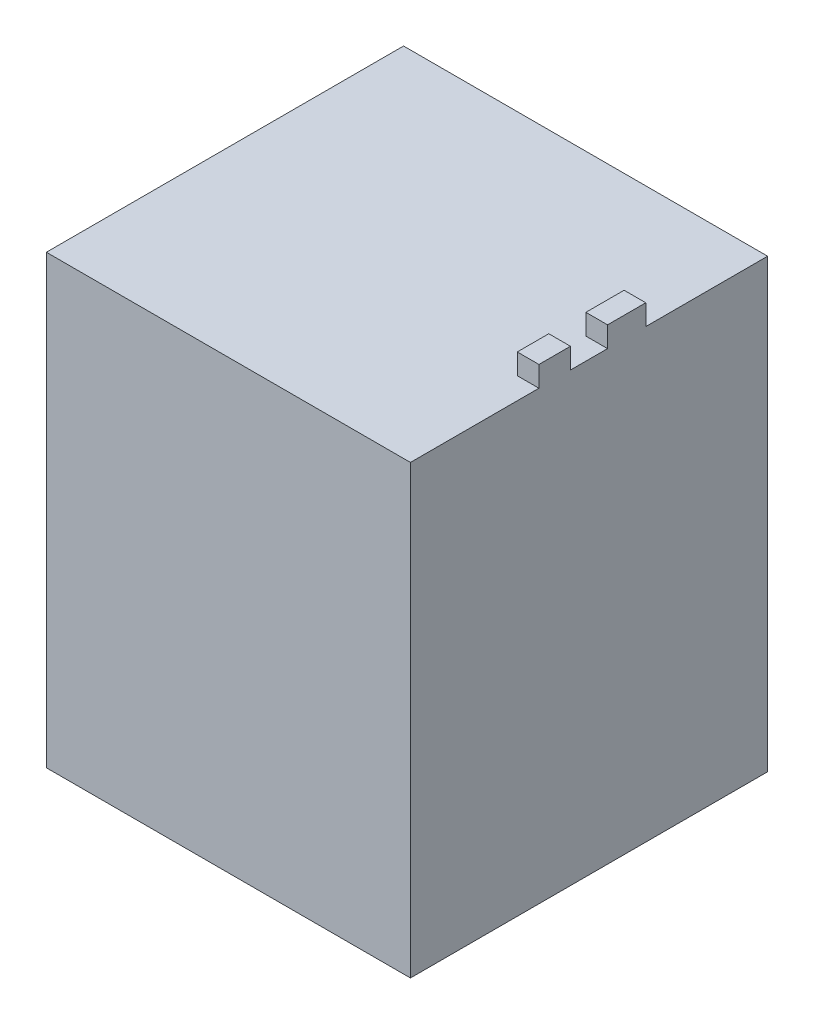
from build123d import *

# Parameters (mm, degrees)
SKETCH1_W           = 53
SKETCH1_H           = 52
BOSS_EXTRUDE1_DEPTH = 65
SKETCH3_W           = 3.15531167
SKETCH3_H           = 5.562756602
SKETCH3_H_2         = 4.588044821
BOSS_EXTRUDE2_DEPTH = 3


with BuildPart() as part:
    # Sketch1 → Boss-Extrude1 (new body)
    with BuildSketch(Plane(origin=(0, 0, 0), x_dir=(1, 0, 0), z_dir=(0, 1, 0))):
        with Locations((14.073446328, 12.824858757)):
            Rectangle(SKETCH1_W, SKETCH1_H)
    extrude(amount=BOSS_EXTRUDE1_DEPTH)

    # Sketch3 → Boss-Extrude2 (add)
    with BuildSketch(Plane(origin=(0, 65, 0), x_dir=(1, 0, 0), z_dir=(0, 1, 0))):
        with Locations((38.995790493, 18.302222915)):
            Rectangle(SKETCH3_W, SKETCH3_H)
        with Locations((38.995790493, 7.824698569)):
            Rectangle(SKETCH3_W, SKETCH3_H_2)
    extrude(amount=BOSS_EXTRUDE2_DEPTH)


solid = part.part
